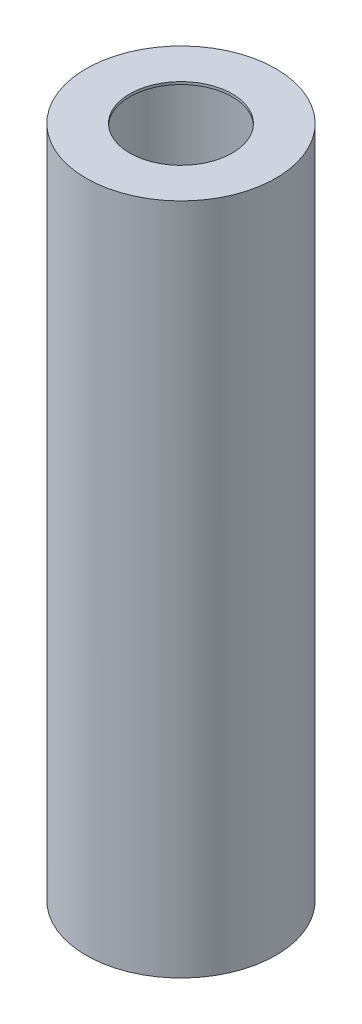
from build123d import *

# Parameters (mm, degrees)
SKETCH1_R           = 9.25
SKETCH1_R_2         = 9
BOSS_EXTRUDE1_DEPTH = 65.1
SKETCH2_R           = 9.25
SKETCH2_R_2         = 5
BOSS_EXTRUDE2_DEPTH = 0.25
SKETCH3_R           = 9.25
SKETCH3_R_2         = 5
BOSS_EXTRUDE3_DEPTH = 0.25


with BuildPart() as part:
    # Sketch1 → Boss-Extrude1 (new body)
    with BuildSketch(Plane(origin=(0, 0, 0), x_dir=(1, 0, 0), z_dir=(0, 1, 0))):
        Circle(SKETCH1_R)
        Circle(SKETCH1_R_2, mode=Mode.SUBTRACT)
    extrude(amount=BOSS_EXTRUDE1_DEPTH)

    # Sketch2 → Boss-Extrude2 (add)
    with BuildSketch(Plane(origin=(0, 65.1, 0), x_dir=(1, 0, 0), z_dir=(0, 1, 0))):
        Circle(SKETCH2_R)
        Circle(SKETCH2_R_2, mode=Mode.SUBTRACT)
    extrude(amount=BOSS_EXTRUDE2_DEPTH)

    # Sketch3 → Boss-Extrude3 (add)
    with BuildSketch(Plane.XZ):
        Circle(SKETCH3_R)
        with Locations((-0.172396434, 0)):
            Circle(SKETCH3_R_2, mode=Mode.SUBTRACT)
    extrude(amount=BOSS_EXTRUDE3_DEPTH)


solid = part.part
